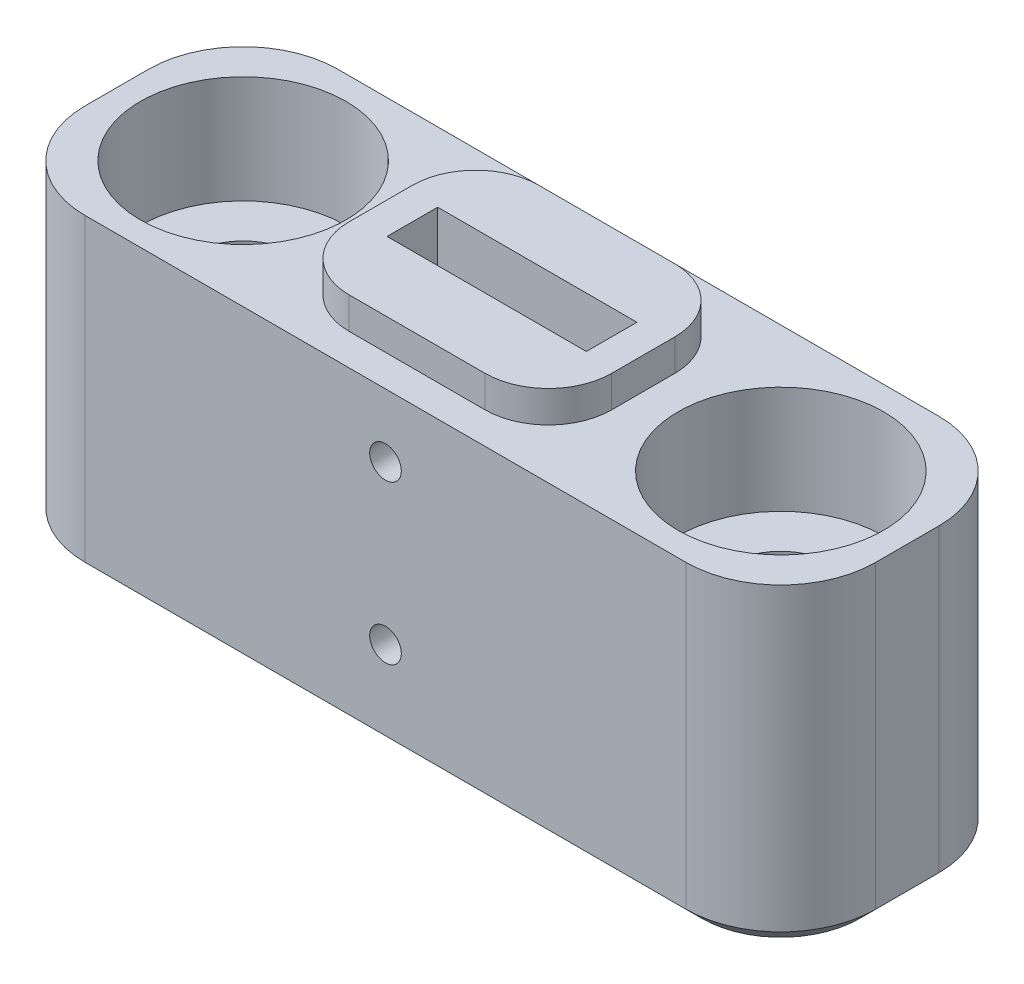
from build123d import *

# Parameters (mm, degrees)
SKIZZE1_W                                            = 25
SKIZZE1_H                                            = 10
AUFSATZ_LINEAR_AUSTRAGEN1_DEPTH                      = 4
STIRNSENKUNG_F_R_M3_ZYLINDERSCHRAUBE_MIT_D           = 3.4
STIRNSENKUNG_F_R_M3_ZYLINDERSCHRAUBE_MIT_CBORE_D     = 6.5
STIRNSENKUNG_F_R_M3_ZYLINDERSCHRAUBE_MIT_CBORE_DEPTH = 3.4
VERRUNDUNG1_R                                        = 3
SKIZZE4_W                                            = 6.3
SKIZZE4_H                                            = 1.6
SCHNITT_LINEAR_AUSTRAGEN1_DEPTH                      = 8
SKIZZE5_W                                            = 8.3
SKIZZE5_H                                            = 6
SKIZZE5_W_2                                          = 6.3
SKIZZE5_H_2                                          = 1.6
AUFSATZ_LINEAR_AUSTRAGEN2_DEPTH                      = 1
VERRUNDUNG2_R                                        = 2
SKIZZE6_R                                            = 0.5
SCHNITT_LINEAR_AUSTRAGEN2_DEPTH                      = 9
FASE1_SIZE                                           = 0.5


with BuildPart() as part:
    # Skizze1 → Aufsatz-Linear austragen1 (new body, symmetric)
    with BuildSketch(Plane.XY):
        Rectangle(SKIZZE1_W, SKIZZE1_H)
    extrude(amount=AUFSATZ_LINEAR_AUSTRAGEN1_DEPTH, both=True)

    # Stirnsenkung für M3 Zylinderschraube mit Innensechskant1 (through all)
    with Locations(Plane(origin=(0, 5, 0), x_dir=(1, 0, 0), z_dir=(0, 1, 0))):
        with Locations((-8.5, 0), (8.5, 0)):
            CounterBoreHole(STIRNSENKUNG_F_R_M3_ZYLINDERSCHRAUBE_MIT_D / 2, STIRNSENKUNG_F_R_M3_ZYLINDERSCHRAUBE_MIT_CBORE_D / 2, STIRNSENKUNG_F_R_M3_ZYLINDERSCHRAUBE_MIT_CBORE_DEPTH)

    # Verrundung1
    verrundung1_edges = [part.edges().sort_by_distance(p)[0] for p in [
        (12.5, 0, 4),
        (-12.5, 0, 4),
        (12.5, 0, -4),
        (-12.5, 0, -4),
    ]]
    fillet(verrundung1_edges, radius=VERRUNDUNG1_R)

    # Skizze4 → Schnitt-Linear austragen1 (cut)
    with BuildSketch(Plane(origin=(0, 5, 0), x_dir=(1, 0, 0), z_dir=(0, 1, 0))):
        Rectangle(SKIZZE4_W, SKIZZE4_H)
    extrude(amount=-SCHNITT_LINEAR_AUSTRAGEN1_DEPTH, mode=Mode.SUBTRACT)

    # Skizze5 → Aufsatz-Linear austragen2 (add)
    with BuildSketch(Plane(origin=(0, 5, 0), x_dir=(1, 0, 0), z_dir=(0, 1, 0))):
        Rectangle(SKIZZE5_W, SKIZZE5_H)
        Rectangle(SKIZZE5_W_2, SKIZZE5_H_2, mode=Mode.SUBTRACT)
    extrude(amount=AUFSATZ_LINEAR_AUSTRAGEN2_DEPTH)

    # Verrundung2
    verrundung2_edges = [part.edges().sort_by_distance(p)[0] for p in [
        (-4.15, 5.5, -3),
        (-4.15, 5.5, 3),
        (4.15, 5.5, 3),
        (4.15, 5.5, -3),
    ]]
    fillet(verrundung2_edges, radius=VERRUNDUNG2_R)

    # Skizze6 → Schnitt-Linear austragen2 (cut, through all)
    with BuildSketch(Plane.XY.offset(4)):
        with Locations((0, 3)):
            Circle(SKIZZE6_R)
        with Locations((0, -2)):
            Circle(SKIZZE6_R)
    extrude(amount=-SCHNITT_LINEAR_AUSTRAGEN2_DEPTH, mode=Mode.SUBTRACT)

    # Fase1
    fase1_edges = [part.edges().sort_by_distance(p)[0] for p in [
        (12.5, -5, 0),
        (0, -5, -4),
        (0, -5, 4),
        (-12.5, -5, 0),
        (-11.621320344, -5, 3.121320344),
        (-11.621320344, -5, -3.121320344),
        (11.621320344, -5, 3.121320344),
        (11.621320344, -5, -3.121320344),
    ]]
    chamfer(fase1_edges, length=FASE1_SIZE)


solid = part.part
